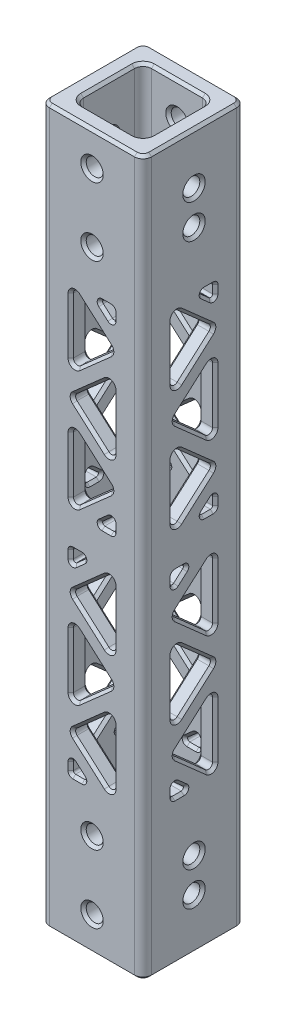
from build123d import *

# Parameters (mm, degrees)
SKETCH1_W                    = 19.05
SKETCH1_H                    = 19.05
SKETCH1_W_2                  = 12.7
SKETCH1_H_2                  = 12.7
BOSS_EXTRUDE1_DEPTH          = 66.675
F_1_8_0_125_DIAMETER_HOLE1_D = 3.175
F_1_8_0_125_DIAMETER_HOLE2_D = 3.175
F_1_8_0_125_DIAMETER_HOLE3_D = 3.175
CUT_EXTRUDE1_START           = -9.525
CUT_EXTRUDE1_DEPTH           = 3.175
CIRPATTERN2_COUNT            = 4
FILLET1_R                    = 1.5875
FILLET2_R                    = 0.79375
FILLET3_R                    = 0.396875
CHAMFER2_SIZE                = 0.508


with BuildPart() as part:
    # Sketch1 → Boss-Extrude1 (new body, symmetric)
    with BuildSketch(Plane(origin=(0, 0, 0), x_dir=(1, 0, 0), z_dir=(0, 1, 0))):
        Rectangle(SKETCH1_W, SKETCH1_H)
        Rectangle(SKETCH1_W_2, SKETCH1_H_2, mode=Mode.SUBTRACT)
    extrude(amount=BOSS_EXTRUDE1_DEPTH, both=True)

    # 1_8 _0.125_ Diameter Hole1 (through all)
    with Locations(Plane.ZY.offset(9.525)):
        with Locations((0, 57.15), (0, 50.8)):
            Hole(F_1_8_0_125_DIAMETER_HOLE1_D / 2)

    # 1_8 _0.125_ Diameter Hole2 (through all)
    with Locations(Plane(origin=(9.525, 0, 0), x_dir=(0, 0, -1), z_dir=(1, 0, 0))):
        with Locations((0, -50.8), (0, -57.15)):
            Hole(F_1_8_0_125_DIAMETER_HOLE2_D / 2)

    # 1_8 _0.125_ Diameter Hole3 (through all)
    with Locations(Plane.XY.offset(9.525)):
        with Locations((0, 60.325), (0, 47.625), (0, -47.625), (0, -60.325)):
            Hole(F_1_8_0_125_DIAMETER_HOLE3_D / 2)

    # Sketch15 → Cut-Extrude1 (cut)
    with BuildSketch(Plane.XY.offset(CUT_EXTRUDE1_START)):
        Polygon((-3.96875, 39.6875), (-0.827576232, 39.6875), (-3.96875, 36.91331643), align=None)
        Polygon((-3.96875, 32.677355477), (3.96875, 39.6875), (3.96875, 25.667210953), align=None)
        Polygon((-3.96875, 28.441394523), (3.96875, 21.43125), (-3.96875, 14.421105477), align=None)
        Polygon((-3.96875, 10.185144523), (3.96875, 17.195289047), (3.96875, 3.175), align=None)
        Polygon((-3.96875, 3.175), (-0.827576232, 3.175), (-3.96875, 5.94918357), align=None)
        Polygon((0.827576232, -3.175), (3.96875, -3.175), (3.96875, -5.94918357), align=None)
        Polygon((-3.96875, -3.175), (3.96875, -10.185144523), (-3.96875, -17.195289047), align=None)
        Polygon((-3.96875, -21.43125), (3.96875, -14.421105477), (3.96875, -28.441394523), align=None)
        Polygon((-3.96875, -39.6875), (3.96875, -32.677355477), (-3.96875, -25.667210953), align=None)
        Polygon((0.827576232, -39.6875), (3.96875, -39.6875), (3.96875, -36.91331643), align=None)
    cut_extrude1 = extrude(amount=CUT_EXTRUDE1_DEPTH, mode=Mode.SUBTRACT)

    # CirPattern2: Cut-Extrude1 ×4 about axis
    cirpattern2_axis = Axis((0, 0, 0), (0, 1, 0))
    for i in range(1, CIRPATTERN2_COUNT):
        add(cut_extrude1.rotate(cirpattern2_axis, i * 360 / CIRPATTERN2_COUNT), mode=Mode.SUBTRACT)

    # Fillet1
    fillet1_edges = [part.edges().sort_by_distance(p)[0] for p in [
        (6.35, 0, 6.35),
        (6.35, 0, -6.35),
        (-6.35, 0, -6.35),
        (-6.35, 0, 6.35),
        (9.525, 0, 9.525),
        (-9.525, 0, 9.525),
        (-9.525, 0, -9.525),
        (9.525, 0, -9.525),
    ]]
    fillet(fillet1_edges, radius=FILLET1_R)

    # Fillet2
    fillet2_edges = [part.edges().sort_by_distance(p)[0] for p in [
        (-3.96875, 14.421105477, -7.9375),
        (-3.96875, 28.441394523, -7.9375),
        (3.96875, 21.43125, -7.9375),
        (3.96875, 3.175, -7.9375),
        (-3.96875, 10.185144523, -7.9375),
        (3.96875, 17.195289047, -7.9375),
        (-3.96875, -17.195289047, -7.9375),
        (-3.96875, -3.175, -7.9375),
        (3.96875, -10.185144523, -7.9375),
        (3.96875, 39.6875, -7.9375),
        (3.96875, 25.667210953, -7.9375),
        (-3.96875, 32.677355477, -7.9375),
        (-3.96875, -39.6875, -7.9375),
        (-3.96875, -25.667210953, -7.9375),
        (3.96875, -32.677355477, -7.9375),
        (3.96875, -28.441394523, -7.9375),
        (-3.96875, -21.43125, -7.9375),
        (3.96875, -14.421105477, -7.9375),
        (-3.96875, 39.6875, 7.9375),
        (-3.96875, 25.667210953, 7.9375),
        (3.96875, 32.677355477, 7.9375),
        (-7.9375, -28.441394523, -3.96875),
        (-7.9375, -21.43125, 3.96875),
        (-7.9375, -14.421105477, -3.96875),
        (3.96875, 14.421105477, 7.9375),
        (3.96875, 28.441394523, 7.9375),
        (-3.96875, 21.43125, 7.9375),
        (3.96875, -39.6875, 7.9375),
        (3.96875, -25.667210953, 7.9375),
        (-3.96875, -32.677355477, 7.9375),
        (-7.9375, -39.6875, 3.96875),
        (-7.9375, -25.667210953, 3.96875),
        (-7.9375, -32.677355477, -3.96875),
        (-7.9375, 39.6875, -3.96875),
        (-7.9375, 25.667210953, -3.96875),
        (-7.9375, 32.677355477, 3.96875),
        (-7.9375, -17.195289047, 3.96875),
        (-7.9375, -3.175, 3.96875),
        (-7.9375, -10.185144523, -3.96875),
        (-7.9375, 3.175, -3.96875),
        (-7.9375, 10.185144523, 3.96875),
        (-7.9375, 17.195289047, -3.96875),
        (-7.9375, 14.421105477, 3.96875),
        (-7.9375, 28.441394523, 3.96875),
        (-7.9375, 21.43125, -3.96875),
        (7.9375, -17.195289047, -3.96875),
        (7.9375, -3.175, -3.96875),
        (7.9375, -10.185144523, 3.96875),
        (7.9375, 3.175, 3.96875),
        (7.9375, 10.185144523, -3.96875),
        (7.9375, 17.195289047, 3.96875),
        (7.9375, 14.421105477, -3.96875),
        (7.9375, 28.441394523, -3.96875),
        (7.9375, 21.43125, 3.96875),
        (7.9375, -28.441394523, 3.96875),
        (7.9375, -21.43125, -3.96875),
        (7.9375, -14.421105477, 3.96875),
        (-3.96875, -28.441394523, 7.9375),
        (3.96875, -21.43125, 7.9375),
        (-3.96875, -14.421105477, 7.9375),
        (3.96875, -17.195289047, 7.9375),
        (3.96875, -3.175, 7.9375),
        (-3.96875, -10.185144523, 7.9375),
        (-3.96875, 3.175, 7.9375),
        (3.96875, 10.185144523, 7.9375),
        (-3.96875, 17.195289047, 7.9375),
        (7.9375, -39.6875, -3.96875),
        (7.9375, -25.667210953, -3.96875),
        (7.9375, -32.677355477, 3.96875),
        (7.9375, 39.6875, 3.96875),
        (7.9375, 25.667210953, 3.96875),
        (7.9375, 32.677355477, -3.96875),
    ]]
    fillet(fillet2_edges, radius=FILLET2_R)

    # Fillet3
    fillet3_edges = [part.edges().sort_by_distance(p)[0] for p in [
        (3.96875, -5.94918357, -7.9375),
        (0.827576232, -3.175, -7.9375),
        (3.96875, -3.175, -7.9375),
        (3.96875, -36.91331643, -7.9375),
        (3.96875, -39.6875, -7.9375),
        (0.827576232, -39.6875, -7.9375),
        (-3.96875, 3.175, -7.9375),
        (-3.96875, 5.94918357, -7.9375),
        (-0.827576232, 3.175, -7.9375),
        (-3.96875, 36.91331643, -7.9375),
        (-3.96875, 39.6875, -7.9375),
        (-0.827576232, 39.6875, -7.9375),
        (-3.96875, -36.91331643, 7.9375),
        (-3.96875, -39.6875, 7.9375),
        (-0.827576232, -39.6875, 7.9375),
        (3.96875, 36.91331643, 7.9375),
        (3.96875, 39.6875, 7.9375),
        (0.827576232, 39.6875, 7.9375),
        (-3.96875, -5.94918357, 7.9375),
        (-0.827576232, -3.175, 7.9375),
        (-3.96875, -3.175, 7.9375),
        (3.96875, 3.175, 7.9375),
        (3.96875, 5.94918357, 7.9375),
        (0.827576232, 3.175, 7.9375),
        (-7.9375, 3.175, 3.96875),
        (-7.9375, 5.94918357, 3.96875),
        (-7.9375, 3.175, 0.827576232),
        (-7.9375, -36.91331643, -3.96875),
        (-7.9375, -39.6875, -3.96875),
        (-7.9375, -39.6875, -0.827576232),
        (-7.9375, -5.94918357, -3.96875),
        (-7.9375, -3.175, -0.827576232),
        (-7.9375, -3.175, -3.96875),
        (7.9375, -5.94918357, 3.96875),
        (7.9375, -3.175, 0.827576232),
        (7.9375, -3.175, 3.96875),
        (7.9375, 36.91331643, -3.96875),
        (7.9375, 39.6875, -3.96875),
        (7.9375, 39.6875, -0.827576232),
        (7.9375, 3.175, -3.96875),
        (7.9375, 5.94918357, -3.96875),
        (7.9375, 3.175, -0.827576232),
        (7.9375, -36.91331643, 3.96875),
        (7.9375, -39.6875, 3.96875),
        (7.9375, -39.6875, 0.827576232),
        (-7.9375, 36.91331643, 3.96875),
        (-7.9375, 39.6875, 3.96875),
        (-7.9375, 39.6875, 0.827576232),
    ]]
    fillet(fillet3_edges, radius=FILLET3_R)

    # Chamfer2
    chamfer2_edges = [part.edges().sort_by_distance(p)[0] for p in [
        (9.525, 3.175, -2.724184334),
        (6.35, 3.175, -2.724184334),
        (9.525, 4.320528112, -3.96875),
        (6.35, 4.320528112, -3.96875),
        (9.525, 4.617999722, -2.461466982),
        (6.35, 4.617999722, -2.461466982),
        (3.96875, -4.320528112, -9.525),
        (3.96875, -4.320528112, -6.35),
        (2.461466982, -4.617999722, -9.525),
        (2.461466982, -4.617999722, -6.35),
        (2.724184334, -3.175, -9.525),
        (2.724184334, -3.175, -6.35),
        (-2.724184334, 3.175, -9.525),
        (-2.724184334, 3.175, -6.35),
        (-3.96875, 4.320528112, -9.525),
        (-3.96875, 4.320528112, -6.35),
        (-2.461466982, 4.617999722, -9.525),
        (-2.461466982, 4.617999722, -6.35),
        (-9.525, 4.617999722, 2.461466982),
        (-6.35, 4.617999722, 2.461466982),
        (-9.525, 3.175, 2.724184334),
        (-6.35, 3.175, 2.724184334),
        (-9.525, 4.320528112, 3.96875),
        (-6.35, 4.320528112, 3.96875),
        (-9.525, -4.320528112, -3.96875),
        (-6.35, -4.320528112, -3.96875),
        (-9.525, -4.617999722, -2.461466982),
        (-6.35, -4.617999722, -2.461466982),
        (-9.525, -3.175, -2.724184334),
        (-6.35, -3.175, -2.724184334),
        (-2.724184334, -3.175, 9.525),
        (-2.724184334, -3.175, 6.35),
        (-3.96875, -4.320528112, 9.525),
        (-3.96875, -4.320528112, 6.35),
        (-2.461466982, -4.617999722, 9.525),
        (-2.461466982, -4.617999722, 6.35),
        (2.461466982, 4.617999722, 9.525),
        (2.461466982, 4.617999722, 6.35),
        (2.724184334, 3.175, 9.525),
        (2.724184334, 3.175, 6.35),
        (3.96875, 4.320528112, 9.525),
        (3.96875, 4.320528112, 6.35),
        (2.724184334, -39.6875, -9.525),
        (2.724184334, -39.6875, -6.35),
        (2.461466982, -38.244500278, -9.525),
        (2.461466982, -38.244500278, -6.35),
        (3.96875, -38.541971888, -9.525),
        (3.96875, -38.541971888, -6.35),
        (-2.461466982, 38.244500278, -9.525),
        (-2.461466982, 38.244500278, -6.35),
        (-3.96875, 38.541971888, -9.525),
        (-3.96875, 38.541971888, -6.35),
        (-2.724184334, 39.6875, -9.525),
        (-2.724184334, 39.6875, -6.35),
        (9.525, -39.6875, 2.724184334),
        (6.35, -39.6875, 2.724184334),
        (9.525, -38.244500278, 2.461466982),
        (6.35, -38.244500278, 2.461466982),
        (9.525, -38.541971888, 3.96875),
        (6.35, -38.541971888, 3.96875),
        (9.525, 38.244500278, -2.461466982),
        (6.35, 38.244500278, -2.461466982),
        (9.525, 38.541971888, -3.96875),
        (6.35, 38.541971888, -3.96875),
        (9.525, 39.6875, -2.724184334),
        (6.35, 39.6875, -2.724184334),
        (-2.724184334, -39.6875, 9.525),
        (-2.724184334, -39.6875, 6.35),
        (-2.461466982, -38.244500278, 9.525),
        (-2.461466982, -38.244500278, 6.35),
        (-3.96875, -38.541971888, 9.525),
        (-3.96875, -38.541971888, 6.35),
        (2.461466982, 38.244500278, 9.525),
        (2.461466982, 38.244500278, 6.35),
        (3.96875, 38.541971888, 9.525),
        (3.96875, 38.541971888, 6.35),
        (2.724184334, 39.6875, 9.525),
        (2.724184334, 39.6875, 6.35),
        (-9.525, -39.6875, -2.724184334),
        (-6.35, -39.6875, -2.724184334),
        (-9.525, -38.244500278, -2.461466982),
        (-6.35, -38.244500278, -2.461466982),
        (-9.525, -38.541971888, -3.96875),
        (-6.35, -38.541971888, -3.96875),
        (-9.525, 38.244500278, 2.461466982),
        (-6.35, 38.244500278, 2.461466982),
        (-9.525, 38.541971888, 3.96875),
        (-6.35, 38.541971888, 3.96875),
        (-9.525, 39.6875, 2.724184334),
        (-6.35, 39.6875, 2.724184334),
        (6.35, -3.291241996, 3.852508004),
        (9.525, -3.291241996, 3.852508004),
        (6.35, -3.431427999, 1.50530045),
        (9.525, -3.431427999, 1.50530045),
        (6.35, -5.430965494, 3.735037215),
        (9.525, -5.430965494, 3.735037215),
        (6.35, 3.291241996, -3.852508004),
        (9.525, 3.291241996, -3.852508004),
        (6.35, 5.430965494, -3.735037215),
        (9.525, 5.430965494, -3.735037215),
        (6.35, 3.431427999, -1.50530045),
        (9.525, 3.431427999, -1.50530045),
        (3.735037215, -5.430965494, -6.35),
        (3.735037215, -5.430965494, -9.525),
        (1.50530045, -3.431427999, -6.35),
        (1.50530045, -3.431427999, -9.525),
        (3.852508004, -3.291241996, -6.35),
        (3.852508004, -3.291241996, -9.525),
        (-3.852508004, 3.291241996, -6.35),
        (-3.852508004, 3.291241996, -9.525),
        (-3.735037215, 5.430965494, -6.35),
        (-3.735037215, 5.430965494, -9.525),
        (-1.50530045, 3.431427999, -6.35),
        (-1.50530045, 3.431427999, -9.525),
        (-6.35, 3.431427999, 1.50530045),
        (-9.525, 3.431427999, 1.50530045),
        (-6.35, 5.430965494, 3.735037215),
        (-9.525, 5.430965494, 3.735037215),
        (-6.35, 3.291241996, 3.852508004),
        (-9.525, 3.291241996, 3.852508004),
        (-6.35, -5.430965494, -3.735037215),
        (-9.525, -5.430965494, -3.735037215),
        (-6.35, -3.431427999, -1.50530045),
        (-9.525, -3.431427999, -1.50530045),
        (-6.35, -3.291241996, -3.852508004),
        (-9.525, -3.291241996, -3.852508004),
        (-3.852508004, -3.291241996, 6.35),
        (-3.852508004, -3.291241996, 9.525),
        (-1.50530045, -3.431427999, 6.35),
        (-1.50530045, -3.431427999, 9.525),
        (-3.735037215, -5.430965494, 6.35),
        (-3.735037215, -5.430965494, 9.525),
        (1.50530045, 3.431427999, 6.35),
        (1.50530045, 3.431427999, 9.525),
        (3.735037215, 5.430965494, 6.35),
        (3.735037215, 5.430965494, 9.525),
        (3.852508004, 3.291241996, 6.35),
        (3.852508004, 3.291241996, 9.525),
        (1.50530045, -39.431072001, -6.35),
        (1.50530045, -39.431072001, -9.525),
        (3.735037215, -37.431534506, -6.35),
        (3.735037215, -37.431534506, -9.525),
        (3.852508004, -39.571258004, -6.35),
        (3.852508004, -39.571258004, -9.525),
        (-3.735037215, 37.431534506, -6.35),
        (-3.735037215, 37.431534506, -9.525),
        (-1.50530045, 39.431072001, -6.35),
        (-1.50530045, 39.431072001, -9.525),
        (-3.852508004, 39.571258004, -6.35),
        (-3.852508004, 39.571258004, -9.525),
        (6.35, -39.431072001, 1.50530045),
        (9.525, -39.431072001, 1.50530045),
        (6.35, -39.571258004, 3.852508004),
        (9.525, -39.571258004, 3.852508004),
        (6.35, -37.431534506, 3.735037215),
        (9.525, -37.431534506, 3.735037215),
        (6.35, 37.431534506, -3.735037215),
        (9.525, 37.431534506, -3.735037215),
        (6.35, 39.431072001, -1.50530045),
        (9.525, 39.431072001, -1.50530045),
        (6.35, 39.571258004, -3.852508004),
        (9.525, 39.571258004, -3.852508004),
        (-1.50530045, -39.431072001, 6.35),
        (-1.50530045, -39.431072001, 9.525),
        (-3.735037215, -37.431534506, 6.35),
        (-3.735037215, -37.431534506, 9.525),
        (-3.852508004, -39.571258004, 6.35),
        (-3.852508004, -39.571258004, 9.525),
        (3.735037215, 37.431534506, 6.35),
        (3.735037215, 37.431534506, 9.525),
        (1.50530045, 39.431072001, 6.35),
        (1.50530045, 39.431072001, 9.525),
        (3.852508004, 39.571258004, 6.35),
        (3.852508004, 39.571258004, 9.525),
        (-6.35, -39.431072001, -1.50530045),
        (-9.525, -39.431072001, -1.50530045),
        (-6.35, -39.571258004, -3.852508004),
        (-9.525, -39.571258004, -3.852508004),
        (-6.35, -37.431534506, -3.735037215),
        (-9.525, -37.431534506, -3.735037215),
        (-6.35, 37.431534506, 3.735037215),
        (-9.525, 37.431534506, 3.735037215),
        (-6.35, 39.571258004, 3.852508004),
        (-9.525, 39.571258004, 3.852508004),
        (-6.35, 39.431072001, 1.50530045),
        (-9.525, 39.431072001, 1.50530045),
        (-6.35, 50.8, 1.5875),
        (6.35, 50.8, 1.5875),
        (9.525, 50.8, 1.5875),
        (-9.525, 50.8, 1.5875),
        (6.35, 57.15, 1.5875),
        (-6.35, 57.15, 1.5875),
        (-9.525, 57.15, 1.5875),
        (9.525, 57.15, 1.5875),
        (0, -66.675, -9.525),
        (0, 66.675, -9.525),
        (9.525, -66.675, 0),
        (0, -66.675, 9.525),
        (-9.525, -66.675, 0),
        (0, -66.675, 6.35),
        (6.35, -66.675, 0),
        (6.35, -57.15, -1.5875),
        (0, -66.675, -6.35),
        (-6.35, -57.15, -1.5875),
        (-6.35, -66.675, 0),
        (-9.060032015, -66.675, 9.060032015),
        (-9.525, -57.15, -1.5875),
        (-9.060032015, -66.675, -9.060032015),
        (9.060032015, -66.675, 9.060032015),
        (9.525, -57.15, -1.5875),
        (9.060032015, -66.675, -9.060032015),
        (9.525, 66.675, 0),
        (-9.525, 66.675, 0),
        (0, 66.675, 9.525),
        (6.35, 66.675, 0),
        (0, 66.675, 6.35),
        (-6.35, 66.675, 0),
        (0, 66.675, -6.35),
        (-9.060032015, 66.675, 9.060032015),
        (-9.060032015, 66.675, -9.060032015),
        (9.060032015, 66.675, 9.060032015),
        (9.060032015, 66.675, -9.060032015),
        (5.885032015, -66.675, -5.885032015),
        (5.885032015, 66.675, -5.885032015),
        (5.885032015, -66.675, 5.885032015),
        (5.885032015, 66.675, 5.885032015),
        (-5.885032015, -66.675, 5.885032015),
        (-5.885032015, 66.675, 5.885032015),
        (-5.885032015, -66.675, -5.885032015),
        (-5.885032015, 66.675, -5.885032015),
        (-0.322768924, -35.897368613, 9.525),
        (-0.322768924, -35.897368613, 6.35),
        (3.96875, -32.677355477, 9.525),
        (3.96875, -32.677355477, 6.35),
        (-0.322768924, -29.45734234, 9.525),
        (-0.322768924, -29.45734234, 6.35),
        (-3.96875, -21.43125, 9.525),
        (-3.96875, -21.43125, 6.35),
        (0.322768924, -24.651263136, 9.525),
        (0.322768924, -24.651263136, 6.35),
        (0.322768924, -18.211236864, 9.525),
        (0.322768924, -18.211236864, 6.35),
        (-0.322768924, -13.40515766, 9.525),
        (-0.322768924, -13.40515766, 6.35),
        (3.96875, -10.185144523, 9.525),
        (3.96875, -10.185144523, 6.35),
        (-0.322768924, -6.965131387, 9.525),
        (-0.322768924, -6.965131387, 6.35),
        (-3.96875, 10.185144523, 9.525),
        (-3.96875, 10.185144523, 6.35),
        (0.322768924, 6.965131387, 9.525),
        (0.322768924, 6.965131387, 6.35),
        (0.322768924, 13.40515766, 9.525),
        (0.322768924, 13.40515766, 6.35),
        (-0.322768924, 18.211236864, 9.525),
        (-0.322768924, 18.211236864, 6.35),
        (-6.35, -50.8, -1.5875),
        (6.35, -50.8, -1.5875),
        (3.96875, 21.43125, 9.525),
        (9.525, -50.8, -1.5875),
        (3.96875, 21.43125, 6.35),
        (-9.525, -50.8, -1.5875),
        (-0.322768924, 24.651263136, 9.525),
        (-0.322768924, 24.651263136, 6.35),
        (-3.96875, 32.677355477, 9.525),
        (-3.96875, 32.677355477, 6.35),
        (0.322768924, 29.45734234, 9.525),
        (0.322768924, 29.45734234, 6.35),
        (0.322768924, 35.897368613, 9.525),
        (0.322768924, 35.897368613, 6.35),
        (9.525, -29.45734234, 0.322768924),
        (6.35, -29.45734234, 0.322768924),
        (9.525, -35.897368613, 0.322768924),
        (6.35, -35.897368613, 0.322768924),
        (9.525, -32.677355477, -3.96875),
        (6.35, -32.677355477, -3.96875),
        (9.525, -21.43125, 3.96875),
        (6.35, -21.43125, 3.96875),
        (9.525, -24.651263136, -0.322768924),
        (6.35, -24.651263136, -0.322768924),
        (9.525, -18.211236864, -0.322768924),
        (6.35, -18.211236864, -0.322768924),
        (9.525, -13.40515766, 0.322768924),
        (6.35, -13.40515766, 0.322768924),
        (9.525, -10.185144523, -3.96875),
        (6.35, -10.185144523, -3.96875),
        (9.525, -6.965131387, 0.322768924),
        (6.35, -6.965131387, 0.322768924),
        (9.525, 10.185144523, 3.96875),
        (6.35, 10.185144523, 3.96875),
        (9.525, 6.965131387, -0.322768924),
        (6.35, 6.965131387, -0.322768924),
        (9.525, 13.40515766, -0.322768924),
        (6.35, 13.40515766, -0.322768924),
        (9.525, 18.211236864, 0.322768924),
        (6.35, 18.211236864, 0.322768924),
        (9.525, 21.43125, -3.96875),
        (6.35, 21.43125, -3.96875),
        (9.525, 24.651263136, 0.322768924),
        (6.35, 24.651263136, 0.322768924),
        (9.525, 32.677355477, 3.96875),
        (6.35, 32.677355477, 3.96875),
        (9.525, 29.45734234, -0.322768924),
        (6.35, 29.45734234, -0.322768924),
        (9.525, 35.897368613, -0.322768924),
        (6.35, 35.897368613, -0.322768924),
        (0.322768924, -35.897368613, -9.525),
        (0.322768924, -35.897368613, -6.35),
        (-3.96875, -32.677355477, -9.525),
        (-3.96875, -32.677355477, -6.35),
        (0.322768924, -29.45734234, -9.525),
        (0.322768924, -29.45734234, -6.35),
        (3.96875, -21.43125, -9.525),
        (3.96875, -21.43125, -6.35),
        (-0.322768924, -24.651263136, -9.525),
        (-0.322768924, -24.651263136, -6.35),
        (-0.322768924, -18.211236864, -9.525),
        (-0.322768924, -18.211236864, -6.35),
        (0.322768924, -13.40515766, -9.525),
        (0.322768924, -13.40515766, -6.35),
        (-3.96875, -10.185144523, -9.525),
        (-3.96875, -10.185144523, -6.35),
        (0.322768924, -6.965131387, -9.525),
        (0.322768924, -6.965131387, -6.35),
        (3.96875, 10.185144523, -9.525),
        (3.96875, 10.185144523, -6.35),
        (-0.322768924, 6.965131387, -9.525),
        (-0.322768924, 6.965131387, -6.35),
        (-0.322768924, 13.40515766, -9.525),
        (-0.322768924, 13.40515766, -6.35),
        (0.322768924, 18.211236864, -9.525),
        (0.322768924, 18.211236864, -6.35),
        (-3.96875, 21.43125, -9.525),
        (-3.96875, 21.43125, -6.35),
        (0.322768924, 24.651263136, -9.525),
        (0.322768924, 24.651263136, -6.35),
        (3.96875, 32.677355477, -9.525),
        (3.96875, 32.677355477, -6.35),
        (-0.322768924, 29.45734234, -9.525),
        (-0.322768924, 29.45734234, -6.35),
        (-0.322768924, 35.897368613, -9.525),
        (-0.322768924, 35.897368613, -6.35),
        (-9.525, -35.897368613, -0.322768924),
        (-6.35, -35.897368613, -0.322768924),
        (-9.525, -32.677355477, 3.96875),
        (-6.35, -32.677355477, 3.96875),
        (-9.525, -29.45734234, -0.322768924),
        (-6.35, -29.45734234, -0.322768924),
        (-9.525, -21.43125, -3.96875),
        (-6.35, -21.43125, -3.96875),
        (-9.525, -24.651263136, 0.322768924),
        (-6.35, -24.651263136, 0.322768924),
        (-9.525, -18.211236864, 0.322768924),
        (-6.35, -18.211236864, 0.322768924),
        (-9.525, -13.40515766, -0.322768924),
        (-6.35, -13.40515766, -0.322768924),
        (-9.525, -10.185144523, 3.96875),
        (-6.35, -10.185144523, 3.96875),
        (-9.525, -6.965131387, -0.322768924),
        (-6.35, -6.965131387, -0.322768924),
        (-9.525, 10.185144523, -3.96875),
        (-6.35, 10.185144523, -3.96875),
        (-9.525, 6.965131387, 0.322768924),
        (-6.35, 6.965131387, 0.322768924),
        (-9.525, 13.40515766, 0.322768924),
        (-6.35, 13.40515766, 0.322768924),
        (-9.525, 18.211236864, -0.322768924),
        (-6.35, 18.211236864, -0.322768924),
        (-9.525, 21.43125, 3.96875),
        (-6.35, 21.43125, 3.96875),
        (-9.525, 24.651263136, -0.322768924),
        (1.5875, -60.325, 6.35),
        (-6.35, 24.651263136, -0.322768924),
        (1.5875, -60.325, -6.35),
        (-9.525, 29.45734234, 0.322768924),
        (1.5875, -60.325, -9.525),
        (-6.35, 29.45734234, 0.322768924),
        (1.5875, -60.325, 9.525),
        (-9.525, 35.897368613, 0.322768924),
        (-6.35, 35.897368613, 0.322768924),
        (-9.525, 32.677355477, -3.96875),
        (-6.35, 32.677355477, -3.96875),
        (3.50132443, -38.651063847, 6.35),
        (3.50132443, -38.651063847, 9.525),
        (3.50132443, -26.703647106, 6.35),
        (3.50132443, -26.703647106, 9.525),
        (-3.563418442, -32.677355477, 6.35),
        (-3.563418442, -32.677355477, 9.525),
        (-3.50132443, -27.404958371, 6.35),
        (-3.50132443, -27.404958371, 9.525),
        (3.563418442, -21.43125, 6.35),
        (3.563418442, -21.43125, 9.525),
        (-3.50132443, -15.457541629, 6.35),
        (-3.50132443, -15.457541629, 9.525),
        (3.50132443, -16.158852894, 6.35),
        (3.50132443, -16.158852894, 9.525),
        (3.50132443, -4.211436153, 6.35),
        (3.50132443, -4.211436153, 9.525),
        (-3.563418442, -10.185144523, 6.35),
        (-3.563418442, -10.185144523, 9.525),
        (-3.50132443, 4.211436153, 6.35),
        (-3.50132443, 4.211436153, 9.525),
        (3.563418442, 10.185144523, 6.35),
        (3.563418442, 10.185144523, 9.525),
        (-3.50132443, 16.158852894, 6.35),
        (-3.50132443, 16.158852894, 9.525),
        (3.50132443, 15.457541629, 6.35),
        (3.50132443, 15.457541629, 9.525),
        (3.50132443, 27.404958371, 6.35),
        (3.50132443, 27.404958371, 9.525),
        (-3.563418442, 21.43125, 6.35),
        (-3.563418442, 21.43125, 9.525),
        (-3.50132443, 26.703647106, 6.35),
        (-3.50132443, 26.703647106, 9.525),
        (3.563418442, 32.677355477, 6.35),
        (3.563418442, 32.677355477, 9.525),
        (-3.50132443, 38.651063847, 6.35),
        (-3.50132443, 38.651063847, 9.525),
        (6.35, -32.677355477, 3.563418442),
        (9.525, -32.677355477, 3.563418442),
        (6.35, -38.651063847, -3.50132443),
        (9.525, -38.651063847, -3.50132443),
        (6.35, -26.703647106, -3.50132443),
        (9.525, -26.703647106, -3.50132443),
        (6.35, -27.404958371, 3.50132443),
        (9.525, -27.404958371, 3.50132443),
        (6.35, -15.457541629, 3.50132443),
        (9.525, -15.457541629, 3.50132443),
        (6.35, -21.43125, -3.563418442),
        (9.525, -21.43125, -3.563418442),
        (6.35, -16.158852894, -3.50132443),
        (9.525, -16.158852894, -3.50132443),
        (6.35, -4.211436153, -3.50132443),
        (9.525, -4.211436153, -3.50132443),
        (6.35, -10.185144523, 3.563418442),
        (9.525, -10.185144523, 3.563418442),
        (6.35, 4.211436153, 3.50132443),
        (9.525, 4.211436153, 3.50132443),
        (6.35, 16.158852894, 3.50132443),
        (9.525, 16.158852894, 3.50132443),
        (6.35, 10.185144523, -3.563418442),
        (9.525, 10.185144523, -3.563418442),
        (6.35, 15.457541629, -3.50132443),
        (9.525, 15.457541629, -3.50132443),
        (6.35, 27.404958371, -3.50132443),
        (9.525, 27.404958371, -3.50132443),
        (6.35, 21.43125, 3.563418442),
        (9.525, 21.43125, 3.563418442),
        (6.35, 26.703647106, 3.50132443),
        (9.525, 26.703647106, 3.50132443),
        (6.35, 32.677355477, -3.563418442),
        (9.525, 32.677355477, -3.563418442),
        (6.35, 38.651063847, 3.50132443),
        (9.525, 38.651063847, 3.50132443),
        (-3.50132443, -38.651063847, -6.35),
        (-3.50132443, -38.651063847, -9.525),
        (3.563418442, -32.677355477, -6.35),
        (3.563418442, -32.677355477, -9.525),
        (-3.50132443, -26.703647106, -6.35),
        (-3.50132443, -26.703647106, -9.525),
        (3.50132443, -27.404958371, -6.35),
        (3.50132443, -27.404958371, -9.525),
        (3.50132443, -15.457541629, -6.35),
        (3.50132443, -15.457541629, -9.525),
        (-3.563418442, -21.43125, -6.35),
        (-3.563418442, -21.43125, -9.525),
        (-3.50132443, -16.158852894, -6.35),
        (-3.50132443, -16.158852894, -9.525),
        (-3.50132443, -4.211436153, -6.35),
        (-3.50132443, -4.211436153, -9.525),
        (3.563418442, -10.185144523, -6.35),
        (3.563418442, -10.185144523, -9.525),
        (3.50132443, 4.211436153, -6.35),
        (3.50132443, 4.211436153, -9.525),
        (-3.563418442, 10.185144523, -6.35),
        (-3.563418442, 10.185144523, -9.525),
        (3.50132443, 16.158852894, -6.35),
        (3.50132443, 16.158852894, -9.525),
        (-3.50132443, 15.457541629, -6.35),
        (-3.50132443, 15.457541629, -9.525),
        (-3.50132443, 27.404958371, -6.35),
        (-3.50132443, 27.404958371, -9.525),
        (3.563418442, 21.43125, -6.35),
        (3.563418442, 21.43125, -9.525),
        (3.50132443, 26.703647106, -6.35),
        (3.50132443, 26.703647106, -9.525),
        (-3.563418442, 32.677355477, -6.35),
        (-3.563418442, 32.677355477, -9.525),
        (3.50132443, 38.651063847, -6.35),
        (3.50132443, 38.651063847, -9.525),
        (-6.35, -38.651063847, 3.50132443),
        (-9.525, -38.651063847, 3.50132443),
        (-6.35, -26.703647106, 3.50132443),
        (-9.525, -26.703647106, 3.50132443),
        (-6.35, -32.677355477, -3.563418442),
        (-9.525, -32.677355477, -3.563418442),
        (-6.35, -27.404958371, -3.50132443),
        (-9.525, -27.404958371, -3.50132443),
        (-6.35, -15.457541629, -3.50132443),
        (-9.525, -15.457541629, -3.50132443),
        (-6.35, -21.43125, 3.563418442),
        (-9.525, -21.43125, 3.563418442),
        (-6.35, -16.158852894, 3.50132443),
        (-9.525, -16.158852894, 3.50132443),
        (-6.35, -10.185144523, -3.563418442),
        (-9.525, -10.185144523, -3.563418442),
        (-6.35, -4.211436153, 3.50132443),
        (-9.525, -4.211436153, 3.50132443),
        (-6.35, 4.211436153, -3.50132443),
        (-9.525, 4.211436153, -3.50132443),
        (-6.35, 16.158852894, -3.50132443),
        (-9.525, 16.158852894, -3.50132443),
        (-6.35, 10.185144523, 3.563418442),
        (-9.525, 10.185144523, 3.563418442),
        (-6.35, 15.457541629, 3.50132443),
        (-9.525, 15.457541629, 3.50132443),
        (-6.35, 21.43125, -3.563418442),
        (-9.525, 21.43125, -3.563418442),
        (-6.35, 27.404958371, 3.50132443),
        (-9.525, 27.404958371, 3.50132443),
        (-6.35, 32.677355477, 3.563418442),
        (-9.525, 32.677355477, 3.563418442),
        (-6.35, 26.703647106, -3.50132443),
        (-9.525, 26.703647106, -3.50132443),
        (-6.35, 38.651063847, -3.50132443),
        (-9.525, 38.651063847, -3.50132443),
        (1.5875, -47.625, -6.35),
        (1.5875, -47.625, 6.35),
        (1.5875, -47.625, 9.525),
        (1.5875, -47.625, -9.525),
        (1.5875, 47.625, 6.35),
        (1.5875, 47.625, -6.35),
        (1.5875, 47.625, -9.525),
        (1.5875, 47.625, 9.525),
        (1.5875, 60.325, 6.35),
        (1.5875, 60.325, -6.35),
        (1.5875, 60.325, -9.525),
        (1.5875, 60.325, 9.525),
        (9.525, -3.175, 2.724184334),
        (6.35, -3.175, 2.724184334),
        (9.525, -4.320528112, 3.96875),
        (6.35, -4.320528112, 3.96875),
        (9.525, -4.617999722, 2.461466982),
        (6.35, -4.617999722, 2.461466982),
    ]]
    chamfer(chamfer2_edges, length=CHAMFER2_SIZE)


solid = part.part
